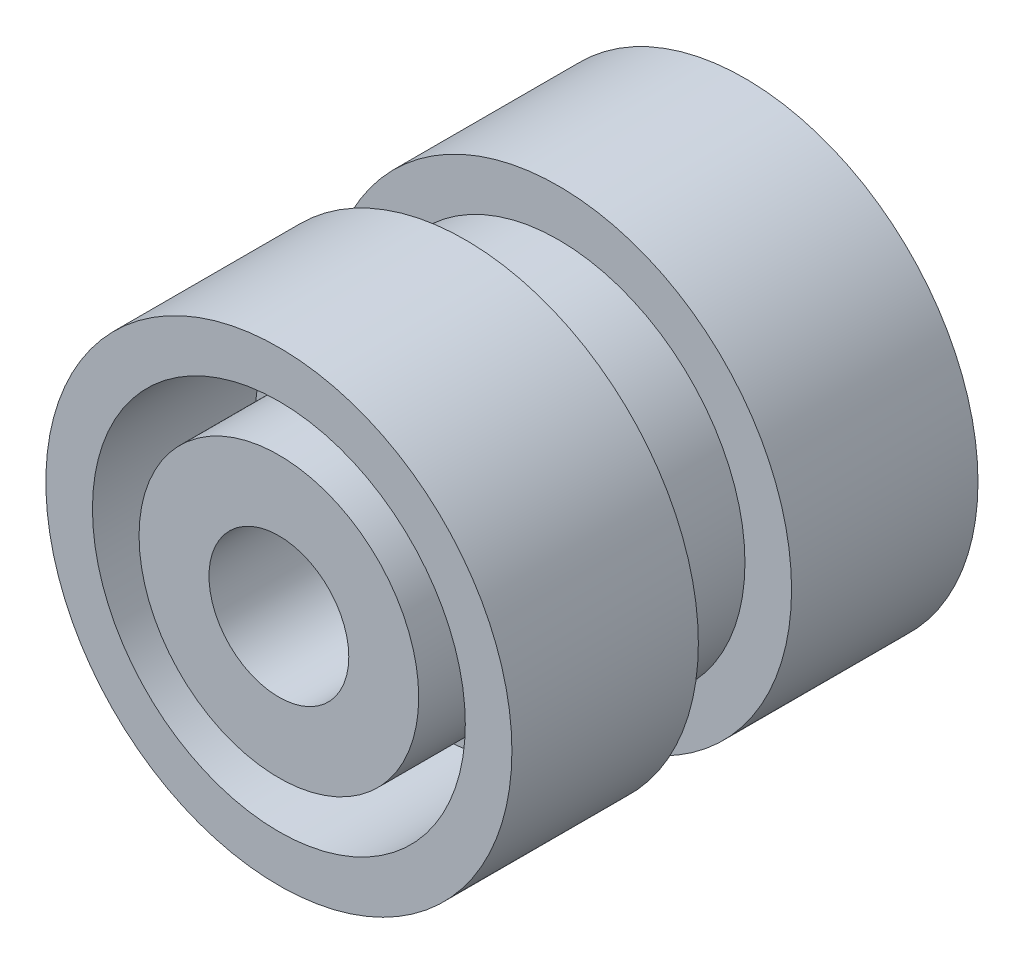
from build123d import *

# Parameters (mm, degrees)
BOSS_EXTRUDE1_DEPTH = 2
SKETCH4_R           = 1.5
CUT_EXTRUDE1_DEPTH  = 8


with BuildPart() as part:
    # Sketch2 → Revolve1 (revolve)
    with BuildSketch(Plane(origin=(0, 0, 0), x_dir=(0, 0, -1), z_dir=(1, 0, 0))):
        Polygon((-5, 0), (-5, 3), (-1.5, 3), (-1.5, 4), (-5, 4), (-5, 5), (-1, 5), (-1, 4), (1, 4), (1, 5), (5, 5), (5, 4), (1.5, 4), (1.5, 0), (0, 0), align=None)
    revolve(axis=Axis((0, 0, 7.451058405), (0, 0, -1)))

    # Sketch3 → Boss-Extrude1 (add)
    with BuildSketch(Plane(origin=(0, 0, -1.5), x_dir=(-1, 0, 0), z_dir=(0, 0, -1))):
        with BuildLine():
            ThreePointArc((1.936491673, 0.5), (1.414213562, 1.414213562), (0.5, 1.936491673))
            Line((0.5, 1.936491673), (0.5, 3.968626967))
            ThreePointArc((0.5, 3.968626967), (0, 4), (-0.5, 3.968626967))
            Line((-0.5, 3.968626967), (-0.5, 1.936491673))
            ThreePointArc((-0.5, 1.936491673), (-1.414213562, 1.414213562), (-1.936491673, 0.5))
            Line((-1.936491673, 0.5), (-3.968626967, 0.5))
            ThreePointArc((-3.968626967, 0.5), (-4, 0), (-3.968626967, -0.5))
            Line((-3.968626967, -0.5), (-1.936491673, -0.5))
            ThreePointArc((-1.936491673, -0.5), (-1.414213562, -1.414213562), (-0.5, -1.936491673))
            Line((-0.5, -1.936491673), (-0.5, -3.968626967))
            ThreePointArc((-0.5, -3.968626967), (0, -4), (0.5, -3.968626967))
            Line((0.5, -3.968626967), (0.5, -1.936491673))
            ThreePointArc((0.5, -1.936491673), (1.414213562, -1.414213562), (1.936491673, -0.5))
            Line((1.936491673, -0.5), (3.968626967, -0.5))
            ThreePointArc((3.968626967, -0.5), (3.992149037, -0.25049165), (4, 0))
            ThreePointArc((4, 0), (3.992149037, 0.25049165), (3.968626967, 0.5))
            Line((3.968626967, 0.5), (1.936491673, 0.5))
        make_face()
    extrude(amount=BOSS_EXTRUDE1_DEPTH)

    # Sketch4 → Cut-Extrude1 (cut)
    with BuildSketch(Plane.XY.offset(5)):
        Circle(SKETCH4_R)
    extrude(amount=-CUT_EXTRUDE1_DEPTH, mode=Mode.SUBTRACT)


solid = part.part
